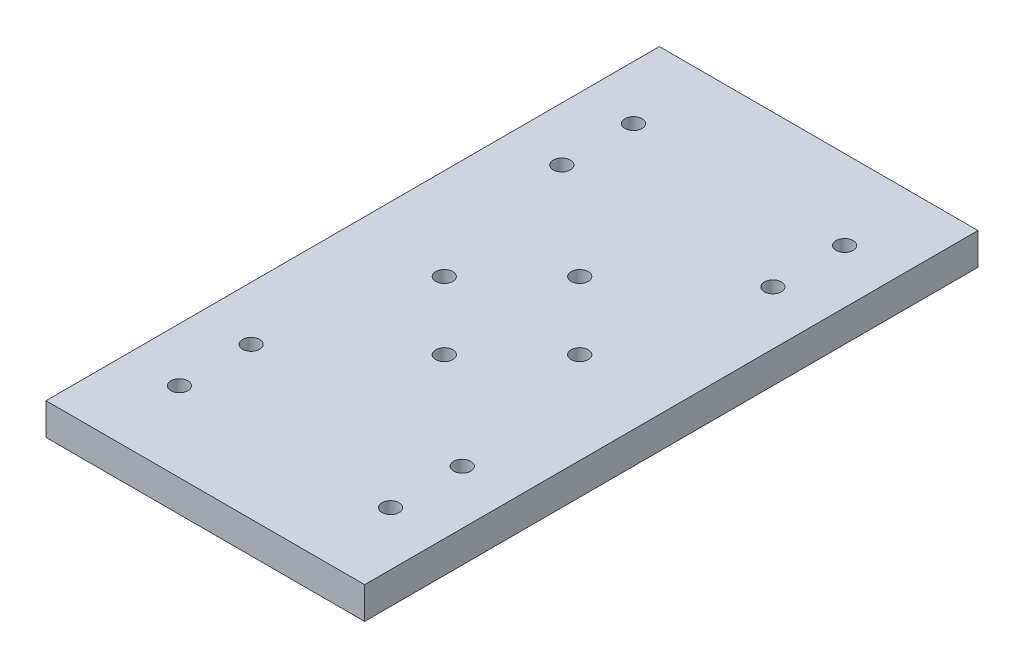
from build123d import *

# Parameters (mm, degrees)
BOSS_EXTRUDE1_DEPTH  = 8
M4_CLEARANCE_HOLE1_D = 4.3
SKETCH4_W            = 80
SKETCH4_H            = 3.5
CUT_EXTRUDE1_DEPTH   = 10
M4_CLEARANCE_HOLE2_D = 4.3


with BuildPart() as part:
    # Sketch1 → Boss-Extrude1 (new body)
    with BuildSketch(Plane(origin=(0, 0, 0), x_dir=(1, 0, 0), z_dir=(0, 1, 0))):
        Polygon((-40, 80.5), (-40, 0), (-40, -80.5), (40, -80.5), (40, 80.5), align=None)
    extrude(amount=BOSS_EXTRUDE1_DEPTH)

    # M4 Clearance Hole1 (through all)
    with Locations(Plane(origin=(0, 8, 0), x_dir=(1, 0, 0), z_dir=(0, 1, 0))):
        with Locations((-26.5, 57), (26.5, 57), (-26.5, 39), (26.5, 39), (26.5, -39), (-26.5, -39), (26.5, -57), (-26.5, -57)):
            Hole(M4_CLEARANCE_HOLE1_D / 2)

    # Sketch4 → Cut-Extrude1 (cut)
    with BuildSketch(Plane(origin=(0, 8, 0), x_dir=(1, 0, 0), z_dir=(0, 1, 0))):
        with Locations((0, 78.75)):
            Rectangle(SKETCH4_W, SKETCH4_H)
        with Locations((0, -78.75)):
            Rectangle(SKETCH4_W, SKETCH4_H)
    extrude(amount=-CUT_EXTRUDE1_DEPTH, mode=Mode.SUBTRACT)

    # M4 Clearance Hole2 (through all)
    with Locations(Plane(origin=(0, 8, 0), x_dir=(1, 0, 0), z_dir=(0, 1, 0))):
        with Locations((-17, 0), (0, 17), (17, 0), (0, -17)):
            Hole(M4_CLEARANCE_HOLE2_D / 2)


solid = part.part
